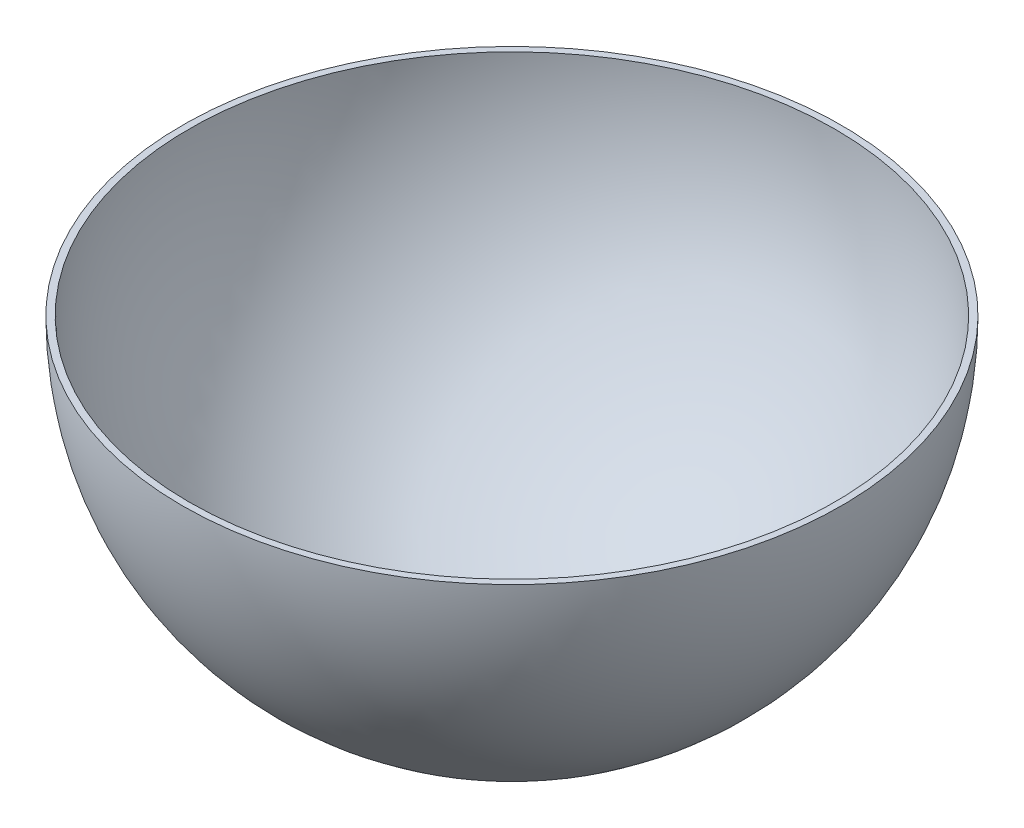
from build123d import *

# Parameters (mm, degrees)
SKETCH_2_R          = 100
CUT_EXTRUDE_1_DEPTH = 101
SKETCH_3_R          = 2.5
CUT_EXTRUDE_2_DEPTH = 101


with BuildPart() as part:
    # 草图1 → 旋转1 (revolve)
    with BuildSketch(Plane.XY):
        with BuildLine():
            Line((-100, 0), (-98, 0))
            ThreePointArc((-98, 0), (0, -98), (98, 0))
            Line((98, 0), (100, 0))
            ThreePointArc((100, 0), (0, -100), (-100, 0))
        make_face()
    revolve(axis=Axis((-100, 0, 0), (1, 0, 0)))

    # 草图2 → 切除-拉伸1 (cut, through all)
    with BuildSketch(Plane(origin=(0, 0, 0), x_dir=(1, 0, 0), z_dir=(0, 1, 0))):
        Circle(SKETCH_2_R)
    extrude(amount=CUT_EXTRUDE_1_DEPTH, mode=Mode.SUBTRACT)

    # 草图3 → 切除-拉伸2 (cut, through all)
    with BuildSketch(Plane(origin=(0, 0, 0), x_dir=(1, 0, 0), z_dir=(0, 1, 0))):
        Circle(SKETCH_3_R)
    extrude(amount=-CUT_EXTRUDE_2_DEPTH, mode=Mode.SUBTRACT)


solid = part.part
